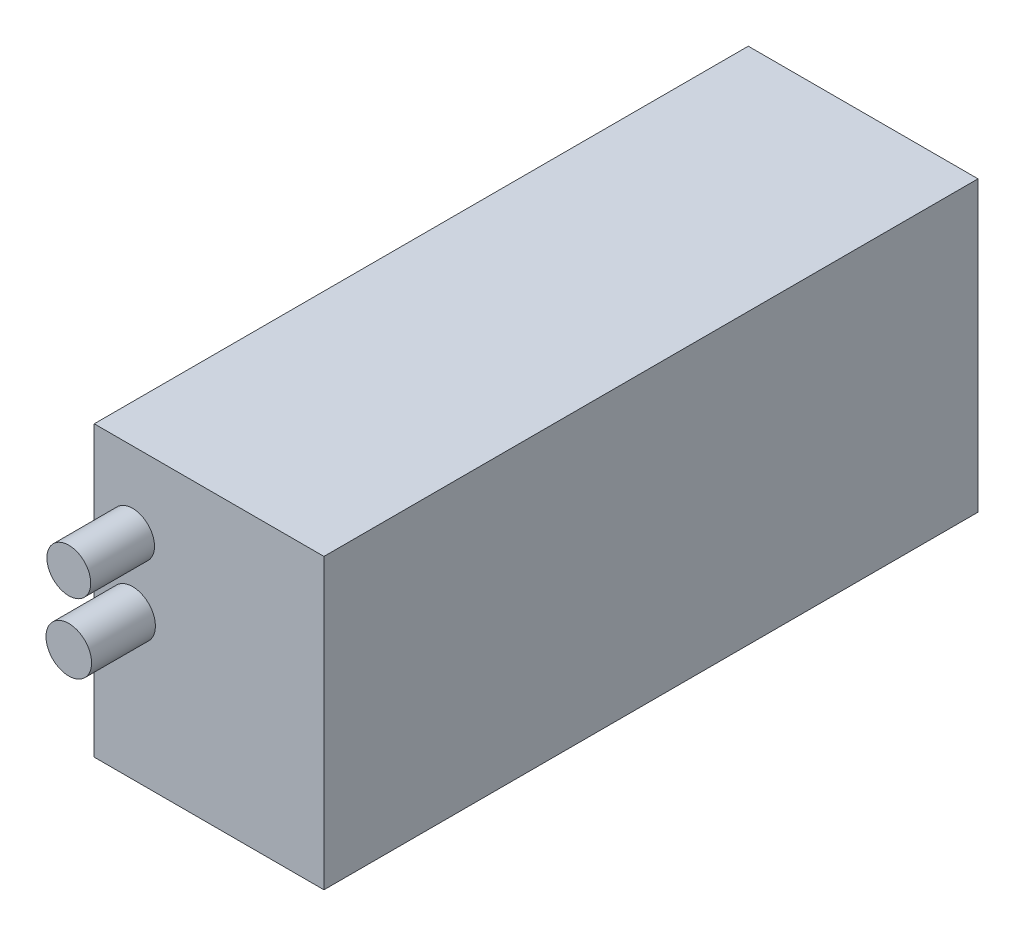
from build123d import *

# Parameters (mm, degrees)
SKETCH1_W           = 72
SKETCH1_H           = 205
BOSS_EXTRUDE1_DEPTH = 90.5
SKETCH3_R           = 6.869769894
SKETCH3_R_2         = 7.145756099
BOSS_EXTRUDE2_DEPTH = 20


with BuildPart() as part:
    # Sketch1 → Boss-Extrude1 (new body)
    with BuildSketch(Plane(origin=(0, 0, 0), x_dir=(1, 0, 0), z_dir=(0, 1, 0))):
        Rectangle(SKETCH1_W, SKETCH1_H)
    extrude(amount=BOSS_EXTRUDE1_DEPTH)

    # Sketch3 → Boss-Extrude2 (add)
    with BuildSketch(Plane.XY.offset(102.5)):
        with Locations((-23.973543761, 66.695088825)):
            Circle(SKETCH3_R)
        with Locations((-23.973543761, 45.176113887)):
            Circle(SKETCH3_R_2)
    extrude(amount=BOSS_EXTRUDE2_DEPTH)


solid = part.part
